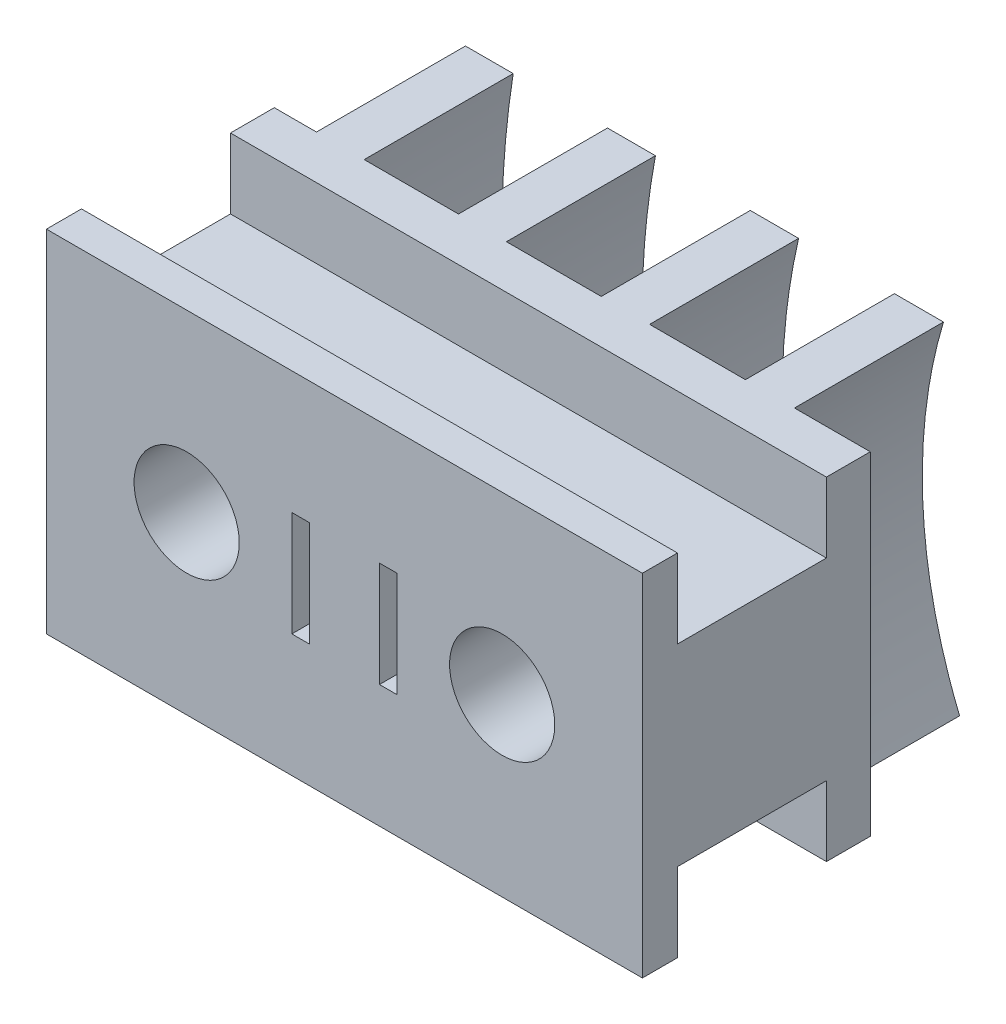
from build123d import *

# Parameters (mm, degrees)
ESQUISSE1_W             = 17
ESQUISSE1_H             = 5.5
BOSS_EXTRU_1_DEPTH      = 5.5
ESQUISSE2_W             = 1.25
ESQUISSE2_H             = 9.5
BOSS_EXTRU_2_DEPTH      = 17
ESQUISSE3_W             = 17
ESQUISSE3_H             = 10
BOSS_EXTRU_3_DEPTH      = 1
ESQUISSE4_R             = 1.5
ENL_V_MAT_EXTRU_1_DEPTH = 3.5
ESQUISSE5_W             = 0.5
ESQUISSE5_H             = 3
ENL_V_MAT_EXTRU_2_DEPTH = 0.5
BOSS_EXTRU_4_DEPTH      = 4.25


with BuildPart() as part:
    # Esquisse1 → Boss.-Extru.1 (new body)
    with BuildSketch(Plane.XY):
        with Locations((20, 0)):
            Rectangle(ESQUISSE1_W, ESQUISSE1_H)
    extrude(amount=-BOSS_EXTRU_1_DEPTH)

    # Esquisse2 → Boss.-Extru.2 (add)
    with BuildSketch(Plane(origin=(28.5, 0, 0), x_dir=(0, 0, -1), z_dir=(1, 0, 0))):
        with Locations((4.875, 0)):
            Rectangle(ESQUISSE2_W, ESQUISSE2_H)
    extrude(amount=-BOSS_EXTRU_2_DEPTH)

    # Esquisse3 → Boss.-Extru.3 (add)
    with BuildSketch(Plane.XY):
        with Locations((20, 0)):
            Rectangle(ESQUISSE3_W, ESQUISSE3_H)
    extrude(amount=BOSS_EXTRU_3_DEPTH)

    # Esquisse4 → Enlèv. mat.-Extru.1 (cut)
    with BuildSketch(Plane.XY.offset(1)):
        with Locations((24.5, 0)):
            Circle(ESQUISSE4_R)
        with Locations((15.5, 0)):
            Circle(ESQUISSE4_R)
    extrude(amount=-ENL_V_MAT_EXTRU_1_DEPTH, mode=Mode.SUBTRACT)

    # Esquisse5 → Enlèv. mat.-Extru.2 (cut)
    with BuildSketch(Plane.XY.offset(1)):
        with Locations((21.25, 0)):
            Rectangle(ESQUISSE5_W, ESQUISSE5_H)
        with Locations((18.75, 0)):
            Rectangle(ESQUISSE5_W, ESQUISSE5_H)
    extrude(amount=-ENL_V_MAT_EXTRU_2_DEPTH, mode=Mode.SUBTRACT)

    # Esquisse6 → Boss.-Extru.4 (add)
    with BuildSketch(Plane(origin=(0, 0, -5.5), x_dir=(-1, 0, 0), z_dir=(0, 0, -1))):
        with BuildLine():
            Line((-22.552794805, -4.75), (-21.148073426, -4.75))
            add(Edge.make_bspline(
                [(-20.826956456, 4.75), (-20.701976007, 4.166184335), (-20.247306857, 1.445543191), (-20.393909727, -1.7940686), (-21.021282717, -4.308854476), (-21.148073426, -4.75)],
                knots=[0.486029583, 0.486029583, 0.486029583, 0.486029583, 0.487632249, 0.493437395, 0.49468936, 0.49468936, 0.49468936, 0.49468936], degree=3))
            Line((-20.826956456, 4.75), (-22.205629087, 4.75))
            add(Edge.make_bspline(
                [(-22.552794805, -4.75), (-22.373592229, -4.173323429), (-21.728969731, -1.663462019), (-21.607804021, 1.583807787), (-22.070035816, 4.161706415), (-22.205629087, 4.75)],
                knots=[0.248115269, 0.248115269, 0.248115269, 0.248115269, 0.249885808, 0.255690519, 0.257428263, 0.257428263, 0.257428263, 0.257428263], degree=3))
        make_face()
        with BuildLine():
            Line((-24.938721269, 4.75), (-26.33817718, 4.75))
            add(Edge.make_bspline(
                [(-26.797581514, -4.75), (-26.395153508, -3.772148074), (-25.672927447, -1.249795135), (-25.669056389, 2.034035882), (-26.163928672, 4.16779276), (-26.33817718, 4.75)],
                knots=[0.135603088, 0.135603088, 0.135603088, 0.135603088, 0.139596288, 0.145400999, 0.147627485, 0.147627485, 0.147627485, 0.147627485], degree=3))
            Line((-26.797581514, -4.75), (-25.352622939, -4.75))
            add(Edge.make_bspline(
                [(-24.938721269, 4.75), (-24.790737954, 4.205700458), (-24.308623009, 1.965116283), (-24.333265983, -1.304768064), (-25.024589159, -3.86460469), (-25.352622939, -4.75)],
                knots=[0.596036757, 0.596036757, 0.596036757, 0.596036757, 0.597930019, 0.603735165, 0.606985384, 0.606985384, 0.606985384, 0.606985384], degree=3))
        make_face()
        with BuildLine():
            Line((-18.401930877, -4.75), (-17.0169294, -4.75))
            add(Edge.make_bspline(
                [(-16.754018342, 4.75), (-16.622548676, 4.006332525), (-16.215434289, 0.825617368), (-16.46223045, -2.389104753), (-17.0169294, -4.75)],
                knots=[0.375646512, 0.375646512, 0.375646512, 0.375646512, 0.377334478, 0.382815018, 0.382815018, 0.382815018, 0.382815018], degree=3))
            Line((-16.754018342, 4.75), (-18.122057744, 4.75))
            add(Edge.make_bspline(
                [(-18.401930877, -4.75), (-18.393480034, -4.716238825), (-17.802884316, -2.332718806), (-17.554252699, 0.889694687), (-17.988042673, 4.036223412), (-18.122057744, 4.75)],
                knots=[0.360091869, 0.360091869, 0.360091869, 0.360091869, 0.360175327, 0.365980039, 0.367700208, 0.367700208, 0.367700208, 0.367700208], degree=3))
        make_face()
        with BuildLine():
            Line((-12.702642178, 4.75), (-14.064547598, 4.75))
            add(Edge.make_bspline(
                [(-14.300001857, -4.75), (-13.846890026, -2.590707185), (-13.586316634, 0.605300957), (-13.912106186, 3.788517123), (-14.064547598, 4.75)],
                knots=[0.471792726, 0.471792726, 0.471792726, 0.471792726, 0.476269559, 0.478227562, 0.478227562, 0.478227562, 0.478227562], degree=3))
            Line((-14.300001857, -4.75), (-12.926181075, -4.75))
            add(Edge.make_bspline(
                [(-12.702642178, 4.75), (-12.548150742, 3.724600153), (-12.249496767, 0.541531469), (-12.507778318, -2.649137977), (-12.926181075, -4.75)],
                knots=[0.265051802, 0.265051802, 0.265051802, 0.265051802, 0.267036708, 0.271169831, 0.271169831, 0.271169831, 0.271169831], degree=3))
        make_face()
    extrude(amount=BOSS_EXTRU_4_DEPTH)


solid = part.part
